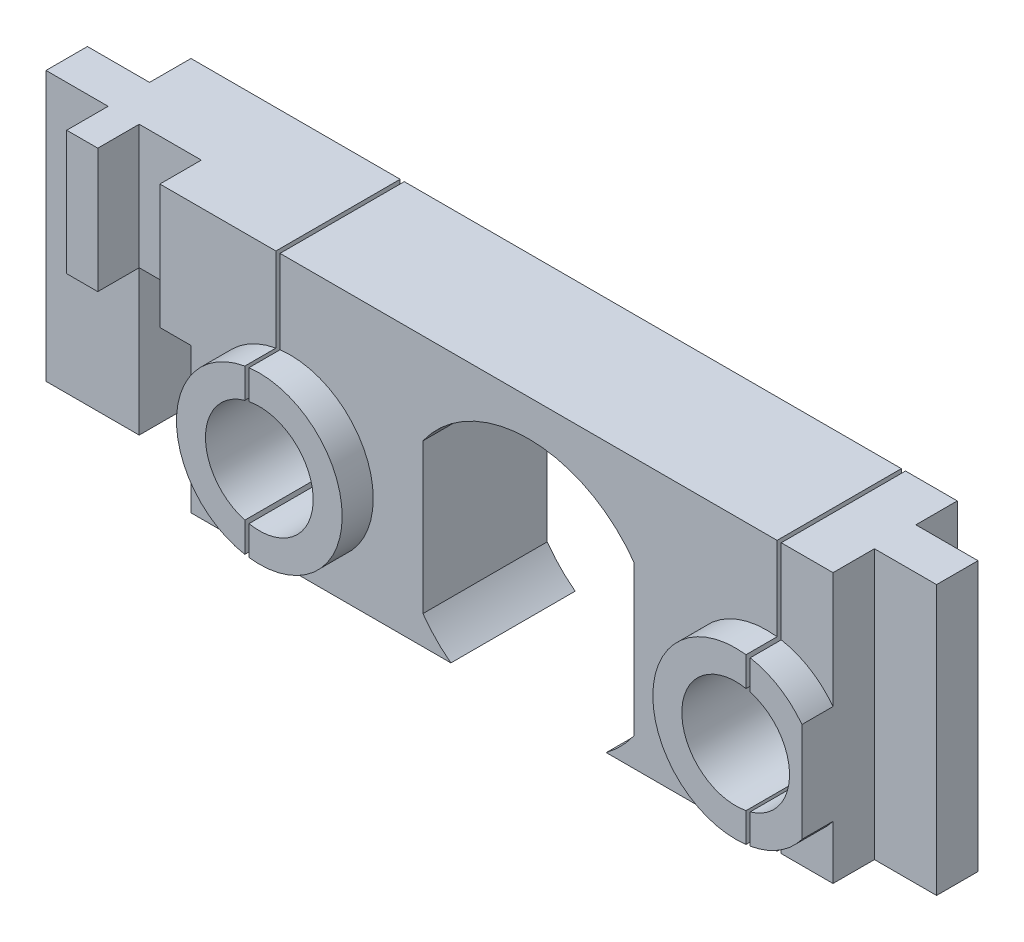
from build123d import *

# Parameters (mm, degrees)
SKETCH1_R           = 1
BOSS_EXTRUDE1_DEPTH = 6
SKETCH2_R           = 2.6
CUT_EXTRUDE1_DEPTH  = 6
SKETCH3_W           = 7.6
SKETCH3_H           = 13
BOSS_EXTRUDE2_DEPTH = 6
BOSS_EXTRUDE5_START = -5
SKETCH6_W           = 3
SKETCH6_H           = 2
BOSS_EXTRUDE5_DEPTH = 13
SKETCH10_R          = 4
SKETCH10_R_2        = 2.6
BOSS_EXTRUDE6_DEPTH = 1.5
SKETCH12_R          = 2.6
SKETCH12_R_2        = 2.4
BOSS_EXTRUDE7_DEPTH = 2
CUT_EXTRUDE2_DEPTH  = 7
SKETCH14_W          = 3
SKETCH14_H          = 2
CUT_EXTRUDE3_DEPTH  = 7
SKETCH15_W          = 0.2
SKETCH15_H          = 13
CUT_EXTRUDE4_DEPTH  = 9.5
SKETCH16_W          = 3
SKETCH16_H          = 3
CUT_EXTRUDE5_DEPTH  = 3
BOSS_EXTRUDE8_START = 0.2
SKETCH16_3_W        = 2.6
SKETCH16_3_H        = 2.6
BOSS_EXTRUDE8_DEPTH = 3
BOSS_EXTRUDE9_START = -24.2
SKETCH16_4_W        = 2.6
SKETCH16_4_H        = 2.6
BOSS_EXTRUDE9_DEPTH = 3


with BuildPart() as part:
    # Sketch1 → Boss-Extrude1 (new body)
    with BuildSketch(Plane.XY):
        with BuildLine():
            ThreePointArc((3.75, -5), (4.47902769, -4.358991965), (5.1, -3.61282438))
            Line((5.1, -3.61282438), (5.1, 3.61282438))
            ThreePointArc((5.1, 3.61282438), (0, 6.25), (-5.1, 3.61282438))
            Line((-5.1, 3.61282438), (-5.1, -3.61282438))
            ThreePointArc((-5.1, -3.61282438), (-4.47902769, -4.358991965), (-3.75, -5))
            Line((-3.75, -5), (-14.7, -5))
            Line((-14.7, -5), (-14.7, 8))
            Line((-14.7, 8), (14.7, 8))
            Line((14.7, 8), (14.7, -5))
            Line((14.7, -5), (3.75, -5))
        make_face()
        with Locations((11.5, 0)):
            Circle(SKETCH1_R, mode=Mode.SUBTRACT)
        with Locations((-11.5, 0)):
            Circle(SKETCH1_R, mode=Mode.SUBTRACT)
    extrude(amount=BOSS_EXTRUDE1_DEPTH)

    # Sketch2 → Cut-Extrude1 (cut)
    with BuildSketch(Plane.XY):
        with Locations((-11.5, 0)):
            Circle(SKETCH2_R)
        with Locations((11.5, 0)):
            Circle(SKETCH2_R)
    extrude(amount=CUT_EXTRUDE1_DEPTH, mode=Mode.SUBTRACT)

    # Sketch3 → Boss-Extrude2 (add)
    with BuildSketch(Plane.XY):
        with Locations((-18.5, 1.5)):
            Rectangle(SKETCH3_W, SKETCH3_H)
    extrude(amount=BOSS_EXTRUDE2_DEPTH)

    # Sketch6 → Boss-Extrude5 (add)
    with BuildSketch(Plane(origin=(0, 0, 0), x_dir=(1, 0, 0), z_dir=(0, 1, 0)).offset(BOSS_EXTRUDE5_START)):
        with Locations((-23.8, -3)):
            Rectangle(SKETCH6_W, SKETCH6_H)
        with Locations((16.2, -3)):
            Rectangle(SKETCH6_W, SKETCH6_H)
    extrude(amount=BOSS_EXTRUDE5_DEPTH)

    # Sketch10 → Boss-Extrude6 (add)
    with BuildSketch(Plane.XY.offset(6)):
        with Locations((-11.5, 0)):
            Circle(SKETCH10_R)
        with Locations((-11.5, 0)):
            Circle(SKETCH10_R_2, mode=Mode.SUBTRACT)
        with BuildLine():
            Line((14.7, 2.4), (14.7, -2.4))
            ThreePointArc((14.7, -2.4), (7.5, 0), (14.7, 2.4))
        make_face()
        with Locations((11.5, 0)):
            Circle(SKETCH10_R_2, mode=Mode.SUBTRACT)
    extrude(amount=BOSS_EXTRUDE6_DEPTH)

    # Sketch12 → Boss-Extrude7 (add)
    with BuildSketch(Plane(origin=(0, 0, 0), x_dir=(-1, 0, 0), z_dir=(0, 0, -1))):
        with Locations((11.5, 0)):
            Circle(SKETCH12_R)
        with Locations((11.5, 0)):
            Circle(SKETCH12_R_2, mode=Mode.SUBTRACT)
        with Locations((-11.5, 0)):
            Circle(SKETCH12_R)
        with Locations((-11.5, 0)):
            Circle(SKETCH12_R_2, mode=Mode.SUBTRACT)
    extrude(amount=-BOSS_EXTRUDE7_DEPTH)

    # Sketch13 → Cut-Extrude2 (cut)
    with BuildSketch(Plane.XZ.offset(5)):
        Polygon((-22.3, 6), (-16.3, 6), (-16.3, 4), (-17.8, 4), (-17.8, 0), (-20.8, 0), (-20.8, 4), (-22.3, 4), align=None)
    extrude(amount=-CUT_EXTRUDE2_DEPTH, mode=Mode.SUBTRACT)

    # Sketch14 → Cut-Extrude3 (cut)
    with BuildSketch(Plane.XZ.offset(-2)):
        with Locations((-19.3, 5)):
            Rectangle(SKETCH14_W, SKETCH14_H)
    extrude(amount=-CUT_EXTRUDE3_DEPTH, mode=Mode.SUBTRACT)

    # Sketch15 → Cut-Extrude4 (cut, symmetric)
    with BuildSketch(Plane.XY):
        with Locations((-12.1, 1.5)):
            Rectangle(SKETCH15_W, SKETCH15_H)
        with Locations((12.1, 1.5)):
            Rectangle(SKETCH15_W, SKETCH15_H)
    extrude(amount=CUT_EXTRUDE4_DEPTH, both=True, mode=Mode.SUBTRACT)

    # Sketch16 → Cut-Extrude5 (cut)
    with BuildSketch(Plane.ZY.offset(12)):
        with Locations((3, 5.173669459)):
            Rectangle(SKETCH16_W, SKETCH16_H)
    cut_extrude5 = extrude(amount=-CUT_EXTRUDE5_DEPTH, mode=Mode.SUBTRACT)

    # Mirror1: Cut-Extrude5 across plane
    add(cut_extrude5.mirror(Plane(origin=(0, 0, 0), x_dir=(0, 0, 1), z_dir=(1, 0, 0))), mode=Mode.SUBTRACT)

    # Sketch16_3 → Boss-Extrude8 (add)
    with BuildSketch(Plane.ZY.offset(12).offset(BOSS_EXTRUDE8_START)):
        with Locations((3, 5.173669459)):
            Rectangle(SKETCH16_3_W, SKETCH16_3_H)
    extrude(amount=-BOSS_EXTRUDE8_DEPTH)

    # Sketch16_4 → Boss-Extrude9 (add)
    with BuildSketch(Plane.ZY.offset(12).offset(BOSS_EXTRUDE9_START)):
        with Locations((3, 5.173669459)):
            Rectangle(SKETCH16_4_W, SKETCH16_4_H)
    extrude(amount=BOSS_EXTRUDE9_DEPTH)


solid = part.part
